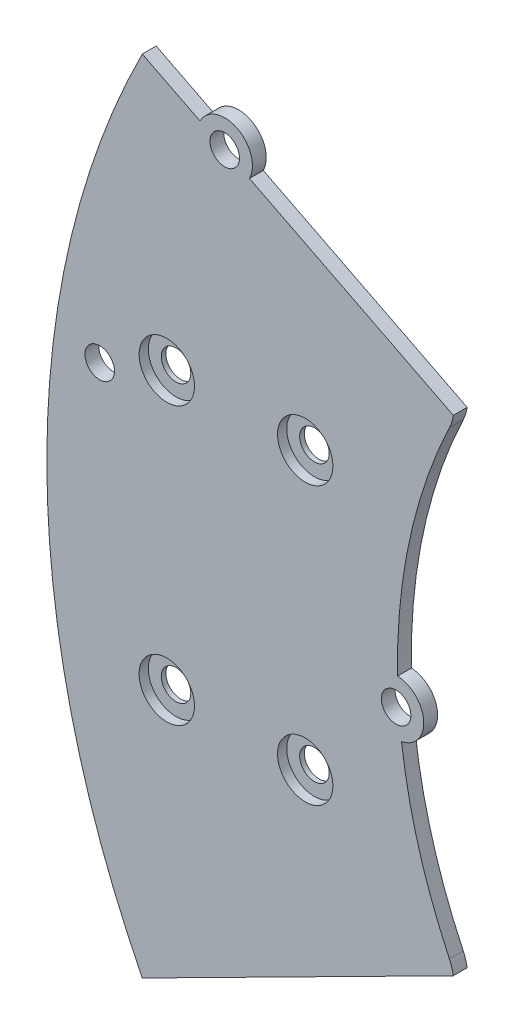
from build123d import *

# Parameters (mm, degrees)
SKETCH1_R           = 1.6
BOSS_EXTRUDE1_DEPTH = 1.5
FILLET1_R           = 5
CUT_EXTRUDE1_DEPTH  = 1.5
SKETCH3_R           = 1.6
CUT_EXTRUDE2_DEPTH  = 1.5
SKETCH4_R           = 3
SKETCH4_R_2         = 1.6
BOSS_EXTRUDE2_DEPTH = 1.5
SKETCH5_R           = 3
CUT_EXTRUDE3_DEPTH  = 1


with BuildPart() as part:
    # Sketch1 → Boss-Extrude1 (new body)
    with BuildSketch(Plane.XY):
        with BuildLine():
            Line((32.770526581, 29), (-0.138438763, 48))
            ThreePointArc((-0.138438763, 48), (-13, 0), (-0.138438763, -48))
            Line((-0.138438763, -48), (32.770526581, -29))
            ThreePointArc((32.770526581, -29), (25, 0), (32.770526581, 29))
        make_face()
        with Locations((0, 15)):
            Circle(SKETCH1_R, mode=Mode.SUBTRACT)
        with Locations((15, 15)):
            Circle(SKETCH1_R, mode=Mode.SUBTRACT)
        with Locations((15, -15)):
            Circle(SKETCH1_R, mode=Mode.SUBTRACT)
        with Locations((0, -15)):
            Circle(SKETCH1_R, mode=Mode.SUBTRACT)
    extrude(amount=BOSS_EXTRUDE1_DEPTH)

    # Fillet1
    fillet1_edges = [part.edges().sort_by_distance(p)[0] for p in [
        (32.770526581, -29, 0.75),
        (-0.138438763, -48, 0.75),
        (-0.138438763, 48, 0.75),
        (32.770526581, 29, 0.75),
    ]]
    fillet(fillet1_edges, radius=FILLET1_R)

    # Sketch2 → Cut-Extrude1 (cut)
    with BuildSketch(Plane.XY.offset(1.5)):
        Polygon((83, 0), (-2.650210769, 43.359444129), (-7.007085146, 61.211012317), (87.93666147, 66.514409607), (145.627275899, 17.878375919), (122.602770589, -61.543232286), (-16.449719346, -74.090294168), (-2.650210769, -43.359444129), align=None)
    extrude(amount=-CUT_EXTRUDE1_DEPTH, mode=Mode.SUBTRACT)

    # Sketch3 → Cut-Extrude2 (cut)
    with BuildSketch(Plane.XY.offset(1.5)):
        with Locations((6.279196304, 38.839033454)):
            Circle(SKETCH3_R)
        with Locations((-7.270629986, 12.073342588)):
            Circle(SKETCH3_R)
        with Locations((24.848199053, -4.18644896)):
            Circle(SKETCH3_R)
    extrude(amount=-CUT_EXTRUDE2_DEPTH, mode=Mode.SUBTRACT)

    # Sketch4 → Boss-Extrude2 (add)
    with BuildSketch(Plane.XY.offset(1.5)):
        with Locations((6.279196304, 38.839033454)):
            Circle(SKETCH4_R)
        with Locations((6.279196304, 38.839033454)):
            Circle(SKETCH4_R_2, mode=Mode.SUBTRACT)
        with Locations((24.848199053, -4.18644896)):
            Circle(SKETCH4_R)
        with Locations((24.848199053, -4.18644896)):
            Circle(SKETCH4_R_2, mode=Mode.SUBTRACT)
    extrude(amount=-BOSS_EXTRUDE2_DEPTH)

    # Sketch5 → Cut-Extrude3 (cut)
    with BuildSketch(Plane.XY.offset(1.5)):
        with Locations((0, 15)):
            Circle(SKETCH5_R)
        with Locations((15, 15)):
            Circle(SKETCH5_R)
        with Locations((15, -15)):
            Circle(SKETCH5_R)
        with Locations((0, -15)):
            Circle(SKETCH5_R)
    extrude(amount=-CUT_EXTRUDE3_DEPTH, mode=Mode.SUBTRACT)


solid = part.part
